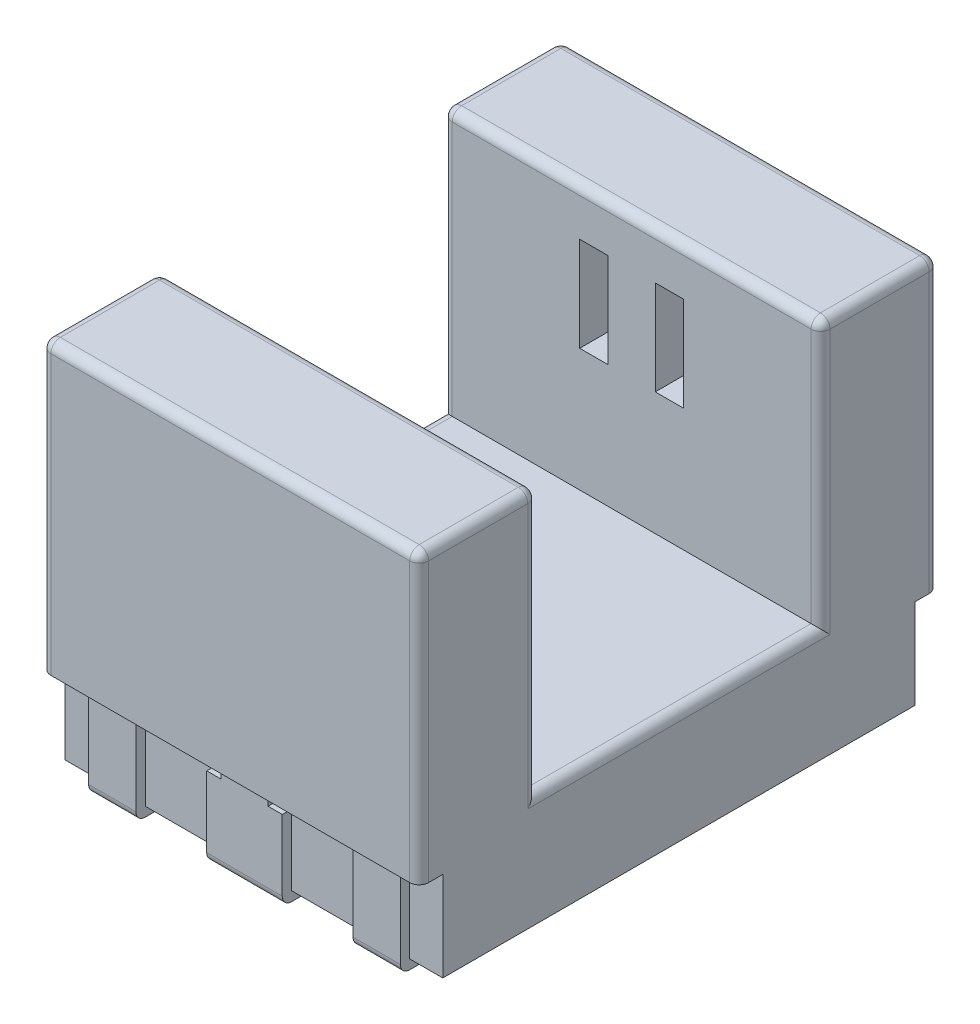
from build123d import *

# Parameters (mm, degrees)
ESQUISSE1_W             = 4
ESQUISSE1_H             = 5
BOSS_EXTRU_1_DEPTH      = 4
ESQUISSE3_W             = 3
ESQUISSE3_H             = 2.8
ENL_V_MAT_EXTRU_1_DEPTH = 4
ESQUISSE4_W             = 4
ESQUISSE4_H             = 3.05
BOSS_EXTRU_2_DEPTH      = 0.25
ESQUISSE5_W             = 0.5
ESQUISSE5_H             = 0.95
BOSS_EXTRU_3_DEPTH      = 0.1
ESQUISSE6_W             = 0.5
ESQUISSE6_H             = 1.02
BOSS_EXTRU_4_DEPTH      = 0.1
ESQUISSE7_W             = 0.8
ESQUISSE7_H             = 1.02
BOSS_EXTRU_5_DEPTH      = 0.1
ESQUISSE8_W             = 0.8
ESQUISSE8_H             = 0.75
BOSS_EXTRU_6_DEPTH      = 0.1
ESQUISSE9_W             = 2.5
ESQUISSE9_H             = 1.5
ENL_V_MAT_EXTRU_2_DEPTH = 0.7
ESQUISSE10_W            = 0.3
ESQUISSE10_H            = 1
ENL_V_MAT_EXTRU_3_DEPTH = 0.3
ESQUISSE11_W            = 0.4
ESQUISSE11_H            = 2
ESQUISSE11_W_2          = 2
ESQUISSE11_H_2          = 0.4
ENL_V_MAT_EXTRU_4_DEPTH = 0.3
CONG_1_R                = 0.1
CONG_2_R                = 0.1
CONG_3_R                = 0.05


with BuildPart() as part:
    # Esquisse1 → Boss.-Extru.1 (new body)
    with BuildSketch(Plane(origin=(0, 0, 0), x_dir=(1, 0, 0), z_dir=(0, 1, 0))):
        Rectangle(ESQUISSE1_W, ESQUISSE1_H)
    extrude(amount=BOSS_EXTRU_1_DEPTH)

    # Esquisse3 → Enlèv. mat.-Extru.1 (cut)
    with BuildSketch(Plane(origin=(2, 0, 0), x_dir=(0, 0, -1), z_dir=(1, 0, 0))):
        with Locations((0, 2.6)):
            Rectangle(ESQUISSE3_W, ESQUISSE3_H)
    extrude(amount=-ENL_V_MAT_EXTRU_1_DEPTH, mode=Mode.SUBTRACT)

    # Esquisse4 → Boss.-Extru.2 (add)
    with BuildSketch(Plane.XY.offset(2.5)):
        with Locations((0, 2.475)):
            Rectangle(ESQUISSE4_W, ESQUISSE4_H)
    boss_extru_2 = extrude(amount=BOSS_EXTRU_2_DEPTH)

    # Symétrie1: Boss.-Extru.2 across plane
    add(boss_extru_2.mirror(Plane.XY))

    # Esquisse5 → Boss.-Extru.3 (add)
    with BuildSketch(Plane.XY.offset(2.5)):
        with Locations((-1.4, 0.475)):
            Rectangle(ESQUISSE5_W, ESQUISSE5_H)
        with Locations((0, 0.475)):
            Rectangle(ESQUISSE5_W, ESQUISSE5_H)
        with Locations((1.4, 0.475)):
            Rectangle(ESQUISSE5_W, ESQUISSE5_H)
    boss_extru_3 = extrude(amount=BOSS_EXTRU_3_DEPTH)

    # Esquisse6 → Boss.-Extru.4 (add)
    with BuildSketch(Plane.XZ):
        with Locations((0, 2.09)):
            Rectangle(ESQUISSE6_W, ESQUISSE6_H)
        with Locations((-1.4, 2.09)):
            Rectangle(ESQUISSE6_W, ESQUISSE6_H)
        with Locations((1.4, 2.09)):
            Rectangle(ESQUISSE6_W, ESQUISSE6_H)
    boss_extru_4 = extrude(amount=BOSS_EXTRU_4_DEPTH)

    # Symétrie2: Boss.-Extru.3, Boss.-Extru.4 across plane
    add(boss_extru_3.mirror(Plane.XY))
    add(boss_extru_4.mirror(Plane.XY))

    # Esquisse7 → Boss.-Extru.5 (add)
    with BuildSketch(Plane.XZ.offset(0.1)):
        with Locations((0, 2.09)):
            Rectangle(ESQUISSE7_W, ESQUISSE7_H)
    extrude(amount=-BOSS_EXTRU_5_DEPTH)

    # Esquisse8 → Boss.-Extru.6 (add)
    with BuildSketch(Plane.XY.offset(2.6)):
        with Locations((0, 0.375)):
            Rectangle(ESQUISSE8_W, ESQUISSE8_H)
    extrude(amount=-BOSS_EXTRU_6_DEPTH)

    # Esquisse9 → Enlèv. mat.-Extru.2 (cut)
    with BuildSketch(Plane(origin=(0, 0, 1.5), x_dir=(-1, 0, 0), z_dir=(0, 0, -1))):
        with Locations((0, 2.75)):
            Rectangle(ESQUISSE9_W, ESQUISSE9_H)
    extrude(amount=-ENL_V_MAT_EXTRU_2_DEPTH, mode=Mode.SUBTRACT)

    # Esquisse10 → Enlèv. mat.-Extru.3 (cut)
    with BuildSketch(Plane.XY.offset(-1.5)):
        with Locations((0.4, 3)):
            Rectangle(ESQUISSE10_W, ESQUISSE10_H)
        with Locations((-0.4, 3)):
            Rectangle(ESQUISSE10_W, ESQUISSE10_H)
    extrude(amount=-ENL_V_MAT_EXTRU_3_DEPTH, mode=Mode.SUBTRACT)

    # Esquisse11 → Enlèv. mat.-Extru.4 (cut)
    with BuildSketch(Plane.XZ):
        Polygon((0.5, -0.6), (0.9, -1), (0.5, -1), align=None)
        Rectangle(ESQUISSE11_W, ESQUISSE11_H)
        Polygon((0.9, 1), (0.5, 1), (0.5, 0.6), align=None)
        Polygon((-0.9, -1), (-0.5, -1), (-0.5, -0.6), align=None)
        Polygon((-0.5, 0.6), (-0.9, 1), (-0.5, 1), align=None)
        Rectangle(ESQUISSE11_W_2, ESQUISSE11_H_2)
    extrude(amount=-ENL_V_MAT_EXTRU_4_DEPTH, mode=Mode.SUBTRACT)

    # Congé1
    cong_1_edges = [part.edges().sort_by_distance(p)[0] for p in [
        (2, 4, 2.125),
        (-2, 4, 2.125),
        (2, 4, -2.125),
        (-2, 2.6, 1.5),
        (0, 4, 1.5),
        (-2, 2.6, -1.5),
        (0, 4, -1.5),
        (-2, 1.2, 0),
        (2, 2.6, 1.5),
        (2, 1.2, 0),
        (2, 2.6, -1.5),
        (-2, 2.475, 2.75),
        (2, 2.475, 2.75),
        (0, 4, 2.75),
        (-2, 2.475, -2.75),
        (0, 4, -2.75),
        (2, 2.475, -2.75),
        (-2, 4, -2.125),
    ]]
    fillet(cong_1_edges, radius=CONG_1_R)

    # Congé2
    cong_2_edges = [part.edges().sort_by_distance(p)[0] for p in [
        (-1.4, -0.1, 2.6),
        (0, -0.1, 2.6),
        (1.4, -0.1, 2.6),
        (-1.4, -0.1, -2.6),
        (0, -0.1, -2.6),
        (1.4, -0.1, -2.6),
    ]]
    fillet(cong_2_edges, radius=CONG_2_R)

    # Congé3
    cong_3_edges = [part.edges().sort_by_distance(p)[0] for p in [
        (0.7, 0, -0.8),
        (-0.2, 0, 0.6),
        (-0.5, 0.15, -0.6),
        (-0.7, 0.3, -0.8),
        (-0.7, 0, -0.8),
        (-0.9, 0.15, -1),
        (-0.7, 0.3, -1),
        (-0.5, 0.15, -1),
        (-0.7, 0, -1),
        (0.6, 0, 0.2),
        (1, 0.15, 0.2),
        (0.2, 0.15, 0.2),
        (1, 0.15, -0.2),
        (0.6, 0, -0.2),
        (0.2, 0.15, -0.2),
        (0.2, 0.15, -1),
        (0, 0, -1),
        (-0.2, 0.15, -1),
        (-0.2, 0, -0.6),
        (-1, 0.15, -0.2),
        (-0.2, 0.15, -0.2),
        (-0.6, 0, -0.2),
        (-0.2, 0.15, 0.2),
        (-1, 0.15, 0.2),
        (-0.6, 0, 0.2),
        (0, 0.3, -1),
        (-0.2, 0.3, -0.6),
        (-0.6, 0.3, -0.2),
        (-1, 0.3, 0),
        (-0.6, 0.3, 0.2),
        (-0.2, 0.3, 0.6),
        (0.2, 0.3, 0.6),
        (0.6, 0.3, 0.2),
        (1, 0.3, 0),
        (0.6, 0.3, -0.2),
        (0.2, 0.3, -0.6),
        (-0.5, 0.3, 0.8),
        (-0.5, 0, 0.8),
        (-0.7, 0.3, 0.8),
        (-0.5, 0.15, 0.6),
        (-0.7, 0, 0.8),
        (-0.5, 0.15, 1),
        (-0.7, 0.3, 1),
        (-0.9, 0.15, 1),
        (-0.7, 0, 1),
        (0.5, 0.3, 0.8),
        (0.5, 0, 0.8),
        (0.7, 0.3, 1),
        (0.5, 0.15, 1),
        (0.7, 0, 1),
        (0.5, 0.15, 0.6),
        (0.7, 0.3, 0.8),
        (0.9, 0.15, 1),
        (0.7, 0, 0.8),
        (0.7, 0.3, -1),
        (0.9, 0.15, -1),
        (0.7, 0, -1),
        (0.5, 0.15, -0.6),
        (0.5, 0.3, -0.8),
        (0.5, 0.15, -1),
        (0.5, 0, -0.8),
        (0.2, 0.15, 1),
        (0, 0.3, 1),
        (-0.2, 0.15, 1),
        (0, 0, 1),
        (0.2, 0, 0.6),
        (1, 0, 0),
        (0.2, 0, -0.6),
        (-1, 0, 0),
        (-0.5, 0, -0.8),
    ]]
    fillet(cong_3_edges, radius=CONG_3_R)


solid = part.part
